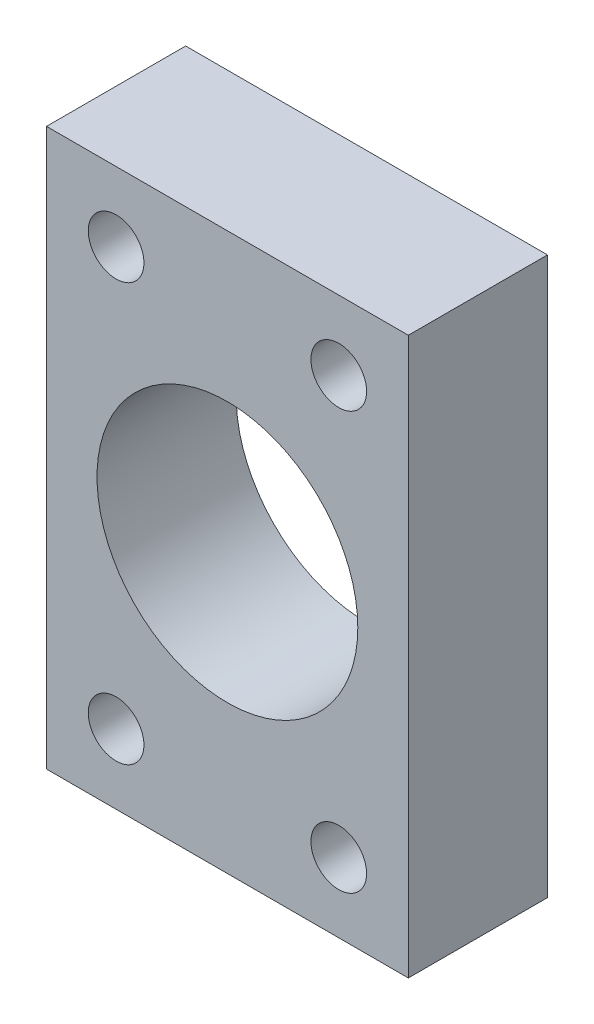
from build123d import *

# Parameters (mm, degrees)
SKETCH1_W           = 33.02
SKETCH1_H           = 50.8
SKETCH1_R           = 2.54
SKETCH1_R_2         = 11.8999
BOSS_EXTRUDE1_DEPTH = 12.7


with BuildPart() as part:
    # Sketch1 → Boss-Extrude1 (new body)
    with BuildSketch(Plane.XY):
        Rectangle(SKETCH1_W, SKETCH1_H)
        with Locations((-10.16, 19.05)):
            Circle(SKETCH1_R, mode=Mode.SUBTRACT)
        with Locations((10.16, 19.05)):
            Circle(SKETCH1_R, mode=Mode.SUBTRACT)
        with Locations((10.16, -19.05)):
            Circle(SKETCH1_R, mode=Mode.SUBTRACT)
        with Locations((-10.16, -19.05)):
            Circle(SKETCH1_R, mode=Mode.SUBTRACT)
        Circle(SKETCH1_R_2, mode=Mode.SUBTRACT)
    extrude(amount=BOSS_EXTRUDE1_DEPTH)


solid = part.part
